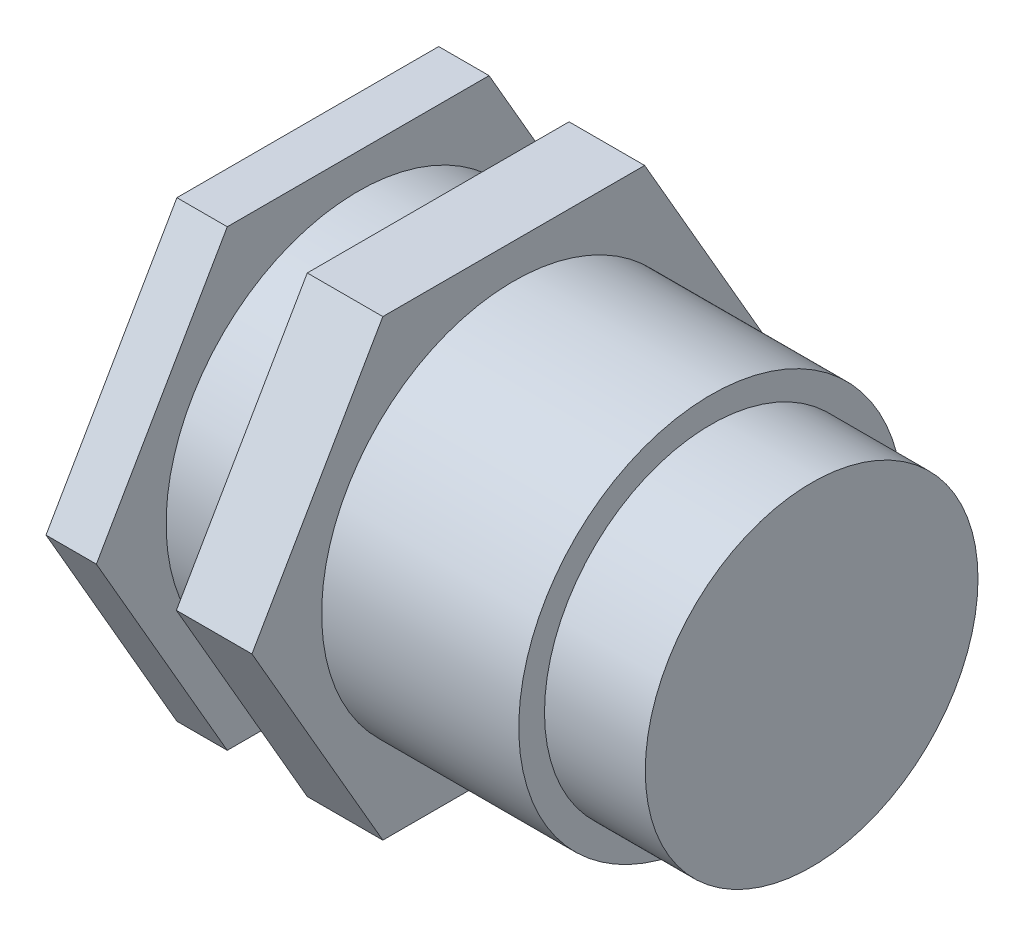
from build123d import *

# Parameters (mm, degrees)
BOSS_EXTRUDE1_DEPTH = 2
SKETCH2_R           = 7.625
BOSS_EXTRUDE2_DEPTH = 14
SKETCH3_R           = 6.604
BOSS_EXTRUDE3_DEPTH = 4
BOSS_EXTRUDE4_START = 3.175
BOSS_EXTRUDE4_DEPTH = 3


with BuildPart() as part:
    # Sketch1 → Boss-Extrude1 (new body)
    with BuildSketch(Plane(origin=(0, 0, 0), x_dir=(0, 0, -1), z_dir=(1, 0, 0))):
        Polygon((5.196152442, 9.000000034), (-5.196152442, 9.000000034), (-10.392304885, 0), (-5.196152442, -9.000000034), (5.196152442, -9.000000034), (10.392304885, 0), align=None)
    extrude(amount=BOSS_EXTRUDE1_DEPTH)

    # Sketch2 → Boss-Extrude2 (add)
    with BuildSketch(Plane(origin=(2, 0, 0), x_dir=(0, 0, -1), z_dir=(1, 0, 0))):
        Circle(SKETCH2_R)
    extrude(amount=BOSS_EXTRUDE2_DEPTH)

    # Sketch3 → Boss-Extrude3 (add)
    with BuildSketch(Plane(origin=(16, 0, 0), x_dir=(0, 0, -1), z_dir=(1, 0, 0))):
        Circle(SKETCH3_R)
    extrude(amount=BOSS_EXTRUDE3_DEPTH)

    # Sketch4 → Boss-Extrude4 (add)
    with BuildSketch(Plane(origin=(2, 0, 0), x_dir=(0, 0, -1), z_dir=(1, 0, 0)).offset(BOSS_EXTRUDE4_START)):
        Polygon((10.392304885, 0), (5.196152442, 9.000000034), (-5.196152442, 9.000000034), (-10.392304885, 0), (-5.196152442, -9.000000034), (5.196152442, -9.000000034), align=None)
    extrude(amount=BOSS_EXTRUDE4_DEPTH)


solid = part.part
